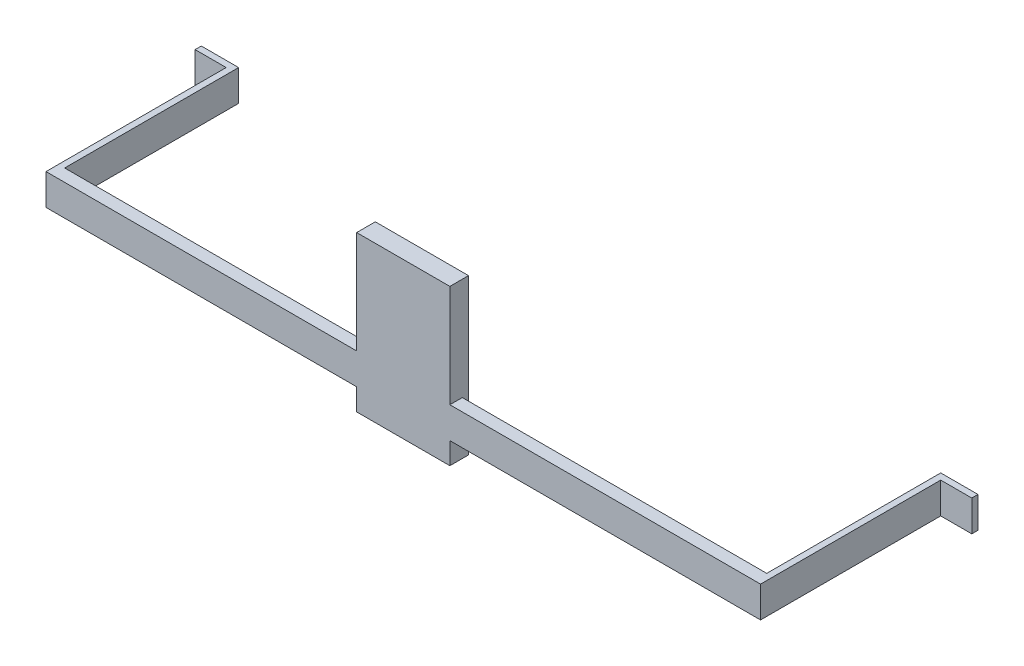
from build123d import *

# Parameters (mm, degrees)
BOSS_EXTRUDE2_DEPTH = 5
SKETCH3_W           = 15
SKETCH3_H           = 25
SKETCH3_W_2         = 13
SKETCH3_H_2         = 23
BOSS_EXTRUDE3_DEPTH = 1
SKETCH5_W           = 15
SKETCH5_H           = 25
BOSS_EXTRUDE5_DEPTH = 2


with BuildPart() as part:
    # Sketch1 → Boss-Extrude2 (new body)
    with BuildSketch(Plane(origin=(0, 0, 0), x_dir=(1, 0, 0), z_dir=(0, 1, 0))):
        Polygon((-57.5, -1), (57.5, -1), (57.5, 28), (62.5, 28), (62.5, 29), (56.5, 29), (56.5, 1), (-56.5, 1), (-56.5, 29), (-62.5, 29), (-62.5, 28), (-57.5, 28), align=None)
    extrude(amount=BOSS_EXTRUDE2_DEPTH)

    # Sketch3 → Boss-Extrude3 (add)
    with BuildSketch(Plane(origin=(0, 0, -1), x_dir=(-1, 0, 0), z_dir=(0, 0, -1))):
        with Locations((0, 9)):
            Rectangle(SKETCH3_W, SKETCH3_H)
        with Locations((0, 9)):
            Rectangle(SKETCH3_W_2, SKETCH3_H_2, mode=Mode.SUBTRACT)
    extrude(amount=BOSS_EXTRUDE3_DEPTH)

    # Sketch5 → Boss-Extrude5 (add)
    with BuildSketch(Plane.XY.offset(-1)):
        with Locations((0, 9)):
            Rectangle(SKETCH5_W, SKETCH5_H)
    extrude(amount=BOSS_EXTRUDE5_DEPTH)


solid = part.part
